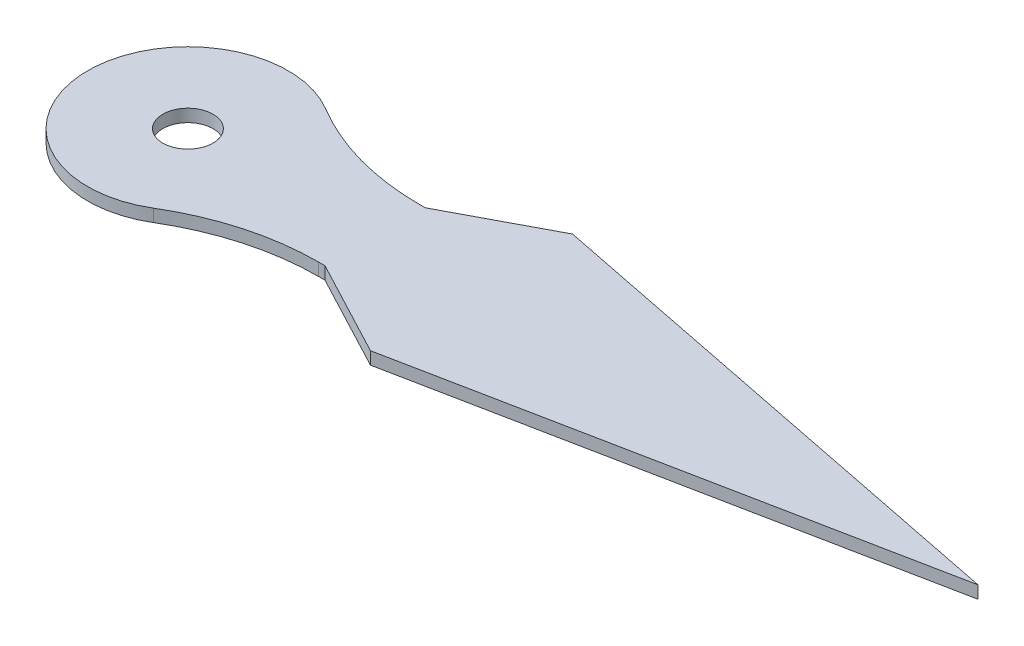
from build123d import *

# Parameters (mm, degrees)
SKETCH1_R           = 4
BOSS_EXTRUDE2_DEPTH = 0.5
FILLET1_R           = 10
SKETCH3_R           = 1
CUT_EXTRUDE2_DEPTH  = 1.5


with BuildPart() as part:
    # Sketch1 → Boss-Extrude2 (new body)
    with BuildSketch(Plane(origin=(0, 0, 0), x_dir=(1, 0, 0), z_dir=(0, 1, 0))):
        with BuildLine():
            Line((7.464101615, 2), (3.464101615, 2))
            ThreePointArc((3.464101615, 2), (3.863703305, 1.03527618), (4, 0))
            ThreePointArc((4, 0), (3.863703305, -1.03527618), (3.464101615, -2))
            Line((3.464101615, -2), (7.464101615, -2))
            Line((7.464101615, -2), (11.302617333, -4.027174803))
            Line((11.302617333, -4.027174803), (31.492947109, 0))
            Line((31.492947109, 0), (11.302617333, 4.027174803))
            Line((11.302617333, 4.027174803), (7.464101615, 2))
        make_face()
        Circle(SKETCH1_R)
    extrude(amount=BOSS_EXTRUDE2_DEPTH)

    # Fillet1
    fillet1_edges = [part.edges().sort_by_distance(p)[0] for p in [
        (3.464101615, 0.25, 2),
        (3.464101615, 0.25, -2),
    ]]
    fillet(fillet1_edges, radius=FILLET1_R)

    # Sketch3 → Cut-Extrude2 (cut, through all)
    with BuildSketch(Plane(origin=(0, 0.5, 0), x_dir=(1, 0, 0), z_dir=(0, 1, 0))):
        Circle(SKETCH3_R)
    extrude(amount=-CUT_EXTRUDE2_DEPTH, mode=Mode.SUBTRACT)


solid = part.part
